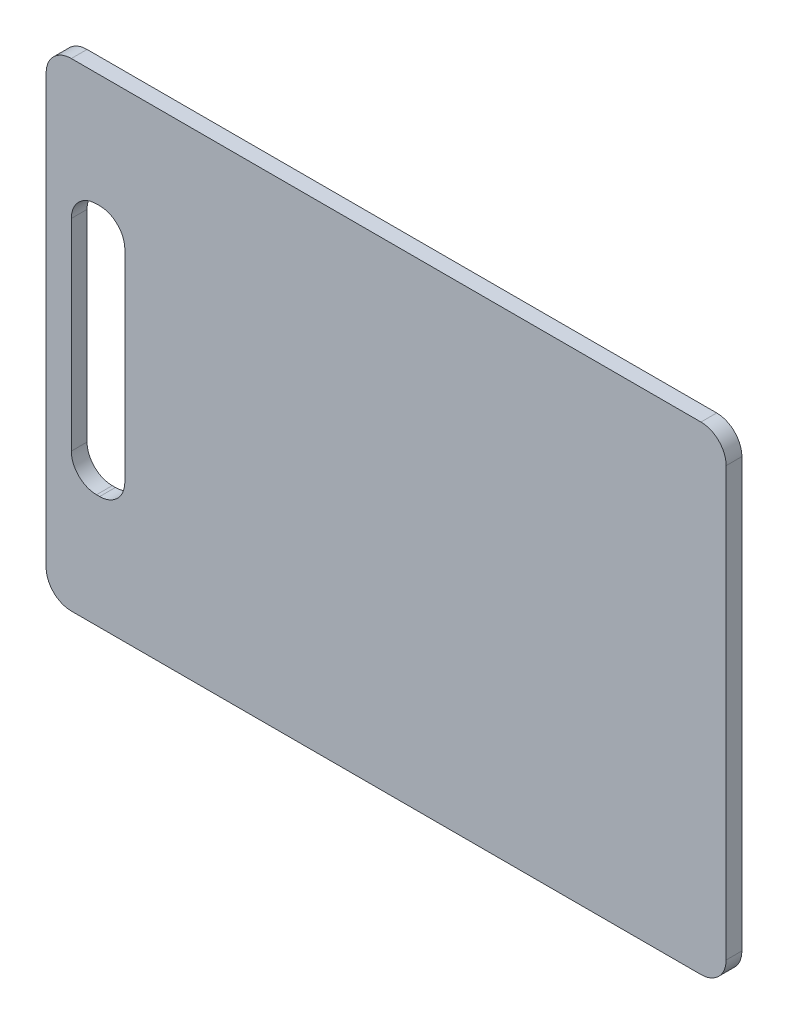
from build123d import *

# Parameters (mm, degrees)
SKETCH1_W           = 342.9
SKETCH1_H           = 241.3
SKETCH1_W_2         = 26.9875
SKETCH1_H_2         = 127
BOSS_EXTRUDE1_DEPTH = 7.9375
FILLET1_R           = 12.7


with BuildPart() as part:
    # Sketch1 → Boss-Extrude1 (new body)
    with BuildSketch(Plane.XY):
        with Locations((-171.45, 120.65)):
            Rectangle(SKETCH1_W, SKETCH1_H)
        with Locations((-316.70625, 120.65)):
            Rectangle(SKETCH1_W_2, SKETCH1_H_2, mode=Mode.SUBTRACT)
    extrude(amount=BOSS_EXTRUDE1_DEPTH)

    # Fillet1
    fillet1_edges = [part.edges().sort_by_distance(p)[0] for p in [
        (-330.2, 184.15, 3.96875),
        (-330.2, 57.15, 3.96875),
        (-303.2125, 57.15, 3.96875),
        (-303.2125, 184.15, 3.96875),
        (-342.9, 241.3, 3.96875),
        (0, 241.3, 3.96875),
        (0, 0, 3.96875),
        (-342.9, 0, 3.96875),
    ]]
    fillet(fillet1_edges, radius=FILLET1_R)


solid = part.part
